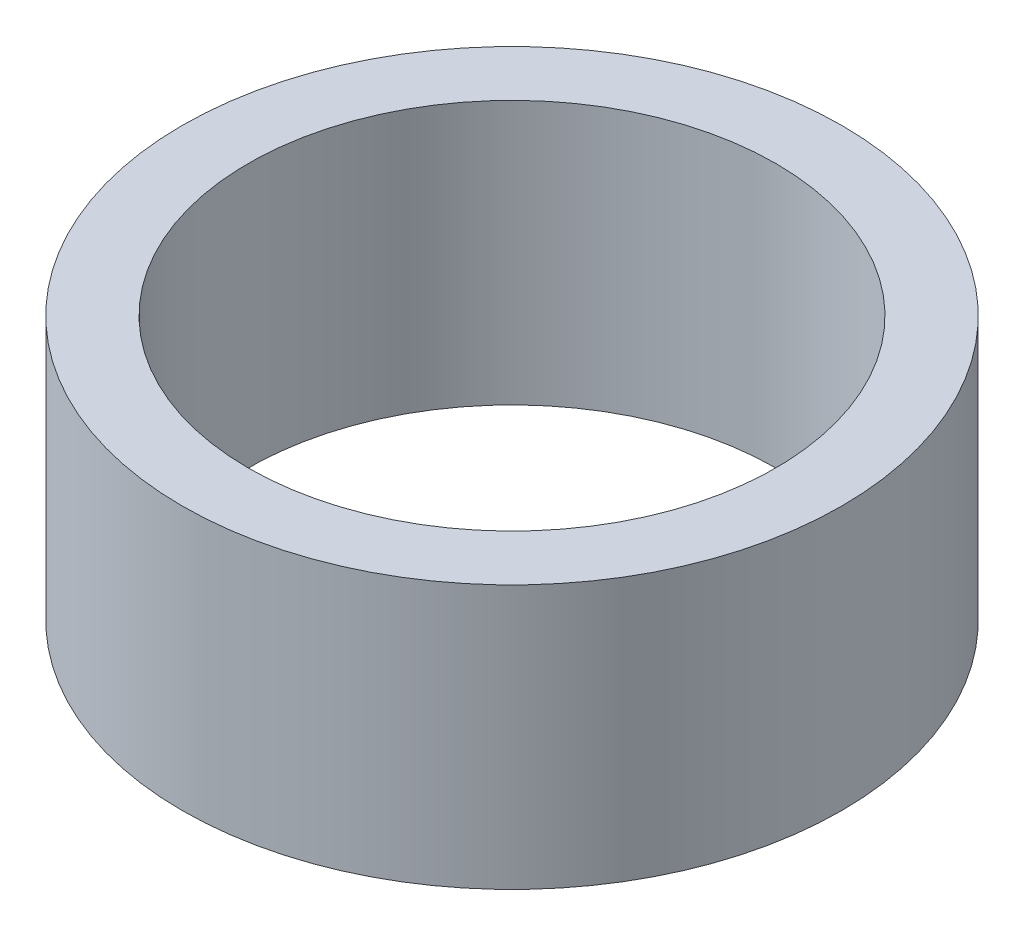
from build123d import *

# Parameters (mm, degrees)
SKETCH3_R           = 25
SKETCH3_R_2         = 20
BOSS_EXTRUDE1_DEPTH = 20


with BuildPart() as part:
    # Sketch3 → Boss-Extrude1 (new body)
    with BuildSketch(Plane(origin=(0, 0, 0), x_dir=(1, 0, 0), z_dir=(0, 1, 0))):
        Circle(SKETCH3_R)
        Circle(SKETCH3_R_2, mode=Mode.SUBTRACT)
    extrude(amount=BOSS_EXTRUDE1_DEPTH)


solid = part.part
